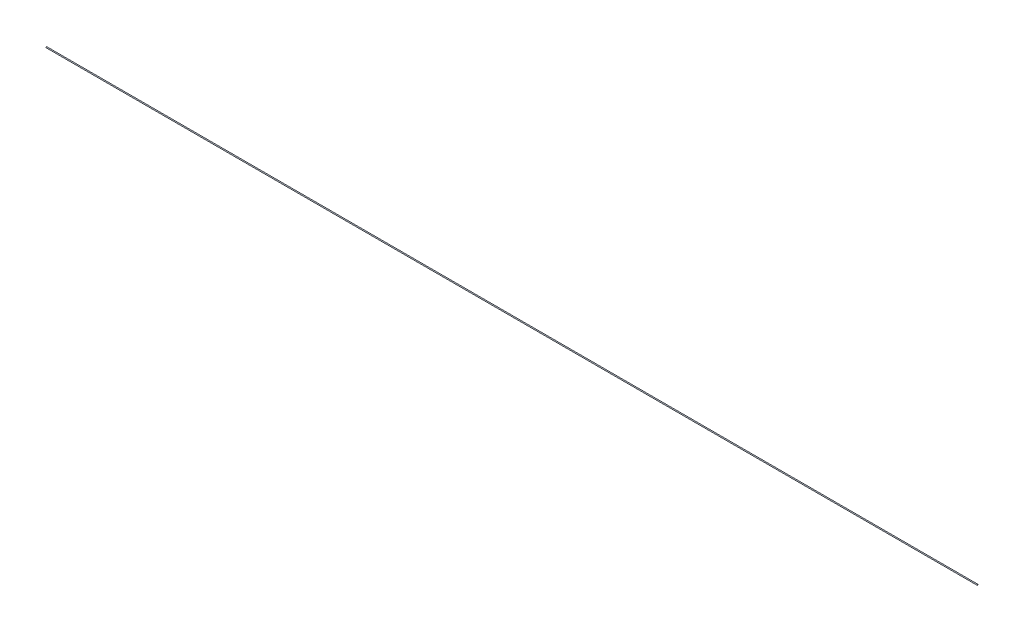
from build123d import *

# Parameters (mm, degrees)
SKETCH1_R           = 0.127
BOSS_EXTRUDE1_DEPTH = 260


with BuildPart() as part:
    # Sketch1 → Boss-Extrude1 (new body)
    with BuildSketch(Plane(origin=(0, 0, 0), x_dir=(0, 0, -1), z_dir=(1, 0, 0))):
        Circle(SKETCH1_R)
    extrude(amount=BOSS_EXTRUDE1_DEPTH)


solid = part.part
